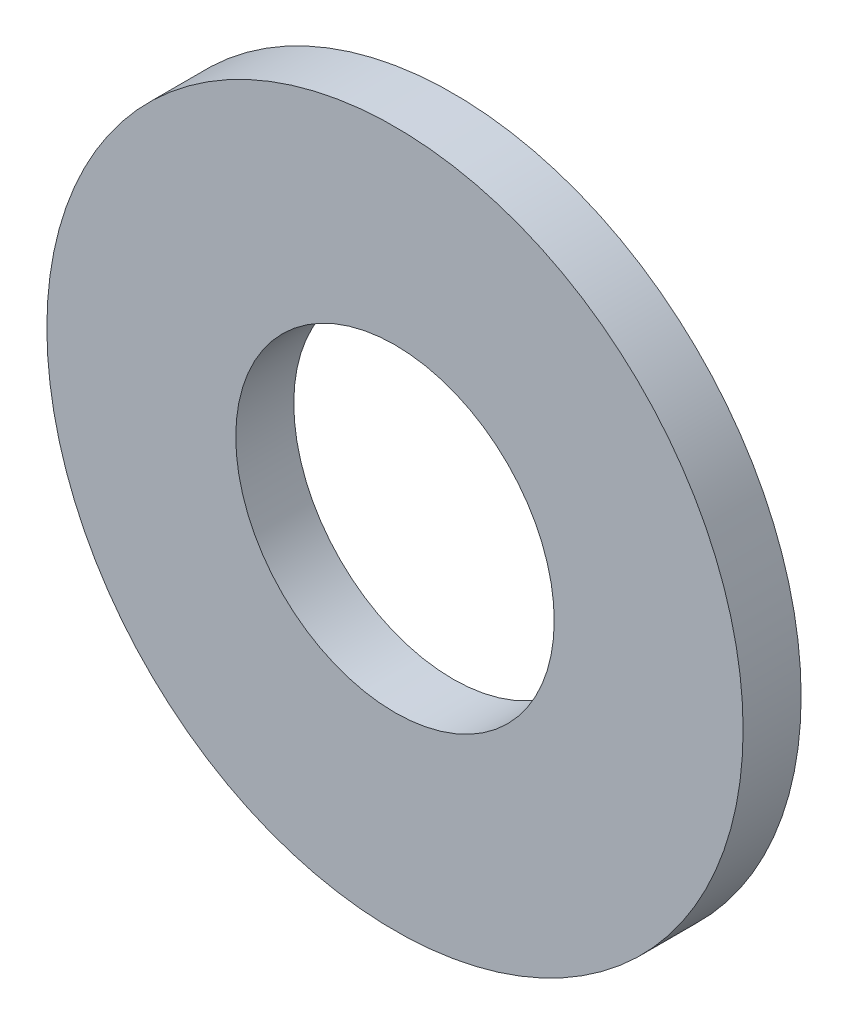
from build123d import *

# Parameters (mm, degrees)
SKETCH1_R           = 4.5
SKETCH1_R_2         = 2.058349178
BOSS_EXTRUDE1_DEPTH = 0.75


with BuildPart() as part:
    # Sketch1 → Boss-Extrude1 (new body)
    with BuildSketch(Plane.XY):
        with Locations((-2.795264869, -4.70072562)):
            Circle(SKETCH1_R)
        with Locations((-2.795264869, -4.70072562)):
            Circle(SKETCH1_R_2, mode=Mode.SUBTRACT)
    extrude(amount=BOSS_EXTRUDE1_DEPTH)


solid = part.part
